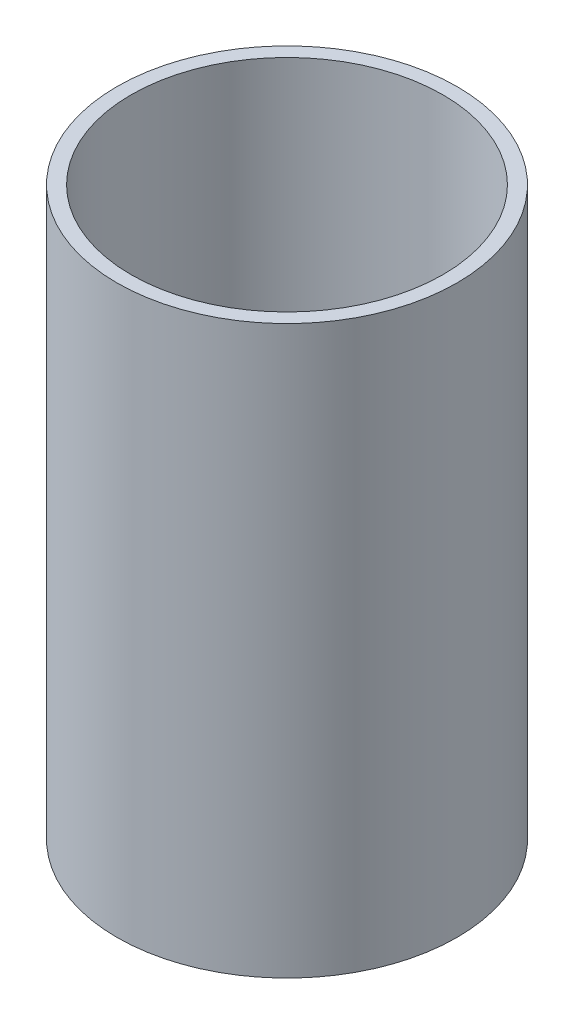
from build123d import *

# Parameters (mm, degrees)
SKETCH2_R           = 38.1
BOSS_EXTRUDE1_DEPTH = 127
SKETCH3_R           = 34.925
CUT_EXTRUDE1_DEPTH  = 127


with BuildPart() as part:
    # Sketch2 → Boss-Extrude1 (new body)
    with BuildSketch(Plane(origin=(0, 0, 0), x_dir=(1, 0, 0), z_dir=(0, 1, 0))):
        Circle(SKETCH2_R)
    extrude(amount=BOSS_EXTRUDE1_DEPTH)

    # Sketch3 → Cut-Extrude1 (cut)
    with BuildSketch(Plane(origin=(0, 127, 0), x_dir=(1, 0, 0), z_dir=(0, 1, 0))):
        Circle(SKETCH3_R)
    extrude(amount=-CUT_EXTRUDE1_DEPTH, mode=Mode.SUBTRACT)


solid = part.part
